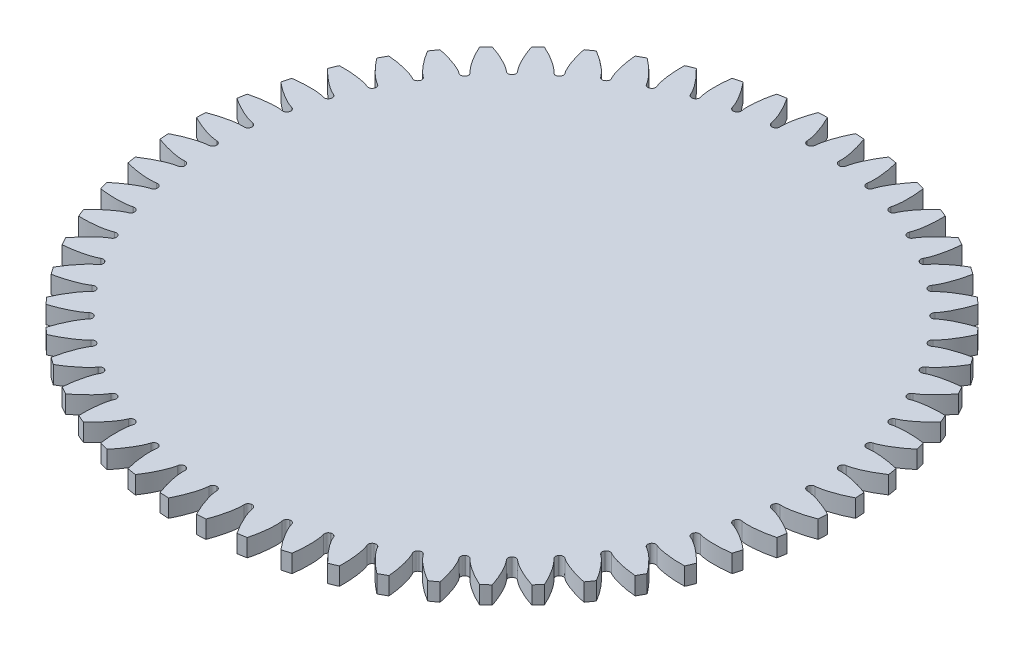
from build123d import *

# Parameters (mm, degrees)
SKETCH1_R                = 118.382142857
BOSS_EXTRUDE1_DEPTH      = 6.35
CUT_EXTRUDE1_DEPTH       = 6.35
FILLET1_R                = 1.369579486
CIRPATTERN2_COUNT        = 56
FILLET1_OF_CIRPATTERN2_R = 1.369579486


with BuildPart() as part:
    # Sketch1 → Boss-Extrude1 (new body)
    with BuildSketch(Plane(origin=(0, 0, 0), x_dir=(1, 0, 0), z_dir=(0, 1, 0))):
        Circle(SKETCH1_R)
    extrude(amount=BOSS_EXTRUDE1_DEPTH)

    # Sketch2 → Cut-Extrude1 (cut)
    with BuildSketch(Plane(origin=(0, 6.35, 0), x_dir=(1, 0, 0), z_dir=(0, 1, 0))):
        with BuildLine():
            Line((107.397586441, 1.411881728), (106.01316094, 1.393681645))
            ThreePointArc((106.01316094, 1.393681645), (106.022321429, 0), (106.01316094, -1.393681645))
            Line((106.01316094, -1.393681645), (107.397586441, -1.411881728))
            add(Edge.make_bspline(
                [(107.397586441, -1.411881728), (107.414640014, -1.412273178), (107.462463824, -1.413889125), (107.552848194, -1.418990064), (107.700290393, -1.430220367), (107.888087637, -1.448804059), (108.130732036, -1.477734499), (108.416446195, -1.518134278), (108.730294702, -1.569156647), (109.07157673, -1.631820907), (109.411887749, -1.700667187), (109.751194021, -1.775240573), (110.089030556, -1.854846983), (110.49804534, -1.95756771), (110.988183211, -2.089487133), (111.560584877, -2.256440262), (112.209156699, -2.460856515), (112.869459916, -2.685326699), (113.51860176, -2.919468999), (114.173745296, -3.171314388), (114.807113624, -3.425810832), (115.464207454, -3.705835066), (116.070337141, -3.972280508), (116.748518174, -4.288180471), (117.295552055, -4.548185322), (117.859858994, -4.83128941), (118.134395944, -4.971221843), (118.274652592, -5.043639719)],
                knots=[0, 0, 0, 0, 0, 0.005376749, 0.015083688, 0.02853182, 0.04661014, 0.064854849, 0.092110526, 0.119476176, 0.146842496, 0.174208854, 0.201574956, 0.228941013, 0.256307345, 0.307035032, 0.361767352, 0.416499661, 0.471231937, 0.525964282, 0.580696616, 0.635428982, 0.690161387, 0.744893688, 0.799626082, 0.854358407, 0.909090914, 0.909090914, 0.909090914, 0.909090914, 0.909090914], degree=4))
            ThreePointArc((118.274652592, -5.043639719), (118.382142857, 0), (118.274652592, 5.043639719))
            add(Edge.make_bspline(
                [(107.397586441, 1.411881728), (107.414640014, 1.412273178), (107.462463824, 1.413889125), (107.552848194, 1.418990064), (107.700290393, 1.430220367), (107.888087637, 1.448804059), (108.130732036, 1.477734499), (108.416446195, 1.518134278), (108.730294702, 1.569156647), (109.07157673, 1.631820907), (109.411887749, 1.700667187), (109.751194021, 1.775240573), (110.089030556, 1.854846983), (110.49804534, 1.95756771), (110.988183211, 2.089487133), (111.560584877, 2.256440262), (112.209156699, 2.460856515), (112.869459916, 2.685326699), (113.51860176, 2.919468999), (114.173745296, 3.171314388), (114.807113624, 3.425810832), (115.464207454, 3.705835066), (116.070337141, 3.972280508), (116.748518174, 4.288180471), (117.295552055, 4.548185322), (117.859858994, 4.83128941), (118.134395944, 4.971221843), (118.274652592, 5.043639719)],
                knots=[0, 0, 0, 0, 0, 0.005376749, 0.015083688, 0.02853182, 0.04661014, 0.064854849, 0.092110526, 0.119476176, 0.146842496, 0.174208854, 0.201574956, 0.228941013, 0.256307345, 0.307035032, 0.361767352, 0.416499661, 0.471231937, 0.525964282, 0.580696616, 0.635428982, 0.690161387, 0.744893688, 0.799626082, 0.854358407, 0.909090914, 0.909090914, 0.909090914, 0.909090914, 0.909090914], degree=4))
        make_face()
    cut_extrude1 = extrude(amount=-CUT_EXTRUDE1_DEPTH, mode=Mode.SUBTRACT)

    # Fillet1
    fillet1_edges = [part.edges().sort_by_distance(p)[0] for p in [
        (106.01316094, 3.175, 1.393681645),
        (106.01316094, 3.175, -1.393681645),
    ]]
    fillet(fillet1_edges, radius=FILLET1_R)

    # CirPattern2: Cut-Extrude1 ×56 about axis
    cirpattern2_axis = Axis((0, 6.35, 0), (0, -1, 0))
    for i in range(1, CIRPATTERN2_COUNT):
        add(cut_extrude1.rotate(cirpattern2_axis, i * 360 / CIRPATTERN2_COUNT), mode=Mode.SUBTRACT)

    # Fillet1 of CirPattern2
    fillet1_of_cirpattern2_edges = [part.edges().sort_by_distance(p)[0] for p in [
        (105.190529601, 3.175, 13.254626492),
        (105.502615271, 3.175, 10.484789558),
        (103.045066318, 3.175, 24.94888672),
        (103.665313001, 3.175, 22.231408448),
        (99.603751539, 3.175, 36.329400222),
        (100.524359271, 3.175, 33.698454478),
        (94.909861792, 3.175, 47.253050438),
        (96.119253398, 3.175, 44.741722891),
        (89.022425466, 3.175, 57.582466128),
        (90.505392144, 3.175, 55.222338179),
        (82.015480487, 3.175, 67.187748895),
        (83.753373072, 3.175, 65.008500523),
        (73.977143254, 3.175, 75.948106738),
        (75.948106738, 3.175, 73.977143254),
        (65.008500523, 3.175, 83.753373072),
        (67.187748895, 3.175, 82.015480487),
        (55.222338179, 3.175, 90.505392144),
        (57.582466128, 3.175, 89.022425466),
        (44.741722891, 3.175, 96.119253398),
        (47.253050438, 3.175, 94.909861792),
        (33.698454478, 3.175, 100.524359271),
        (36.329400222, 3.175, 99.603751539),
        (22.231408448, 3.175, 103.665313001),
        (24.94888672, 3.175, 103.045066318),
        (10.484789558, 3.175, 105.502615271),
        (13.254626492, 3.175, 105.190529601),
        (-1.393681645, 3.175, 106.01316094),
        (1.393681645, 3.175, 106.01316094),
        (-13.254626492, 3.175, 105.190529601),
        (-10.484789558, 3.175, 105.502615271),
        (-24.94888672, 3.175, 103.045066318),
        (-22.231408448, 3.175, 103.665313001),
        (-36.329400222, 3.175, 99.603751539),
        (-33.698454478, 3.175, 100.524359271),
        (-47.253050438, 3.175, 94.909861792),
        (-44.741722891, 3.175, 96.119253398),
        (-57.582466128, 3.175, 89.022425466),
        (-55.222338179, 3.175, 90.505392144),
        (-67.187748895, 3.175, 82.015480487),
        (-65.008500523, 3.175, 83.753373072),
        (-75.948106738, 3.175, 73.977143254),
        (-73.977143254, 3.175, 75.948106738),
        (-83.753373072, 3.175, 65.008500523),
        (-82.015480487, 3.175, 67.187748895),
        (-90.505392144, 3.175, 55.222338179),
        (-89.022425466, 3.175, 57.582466128),
        (-96.119253398, 3.175, 44.741722891),
        (-94.909861792, 3.175, 47.253050438),
        (-100.524359271, 3.175, 33.698454478),
        (-99.603751539, 3.175, 36.329400222),
        (-103.665313001, 3.175, 22.231408448),
        (-103.045066318, 3.175, 24.94888672),
        (-105.502615271, 3.175, 10.484789558),
        (-105.190529601, 3.175, 13.254626492),
        (-106.01316094, 3.175, -1.393681645),
        (-106.01316094, 3.175, 1.393681645),
        (-105.190529601, 3.175, -13.254626492),
        (-105.502615271, 3.175, -10.484789558),
        (-103.045066318, 3.175, -24.94888672),
        (-103.665313001, 3.175, -22.231408448),
        (-99.603751539, 3.175, -36.329400222),
        (-100.524359271, 3.175, -33.698454478),
        (-94.909861792, 3.175, -47.253050438),
        (-96.119253398, 3.175, -44.741722891),
        (-89.022425466, 3.175, -57.582466128),
        (-90.505392144, 3.175, -55.222338179),
        (-82.015480487, 3.175, -67.187748895),
        (-83.753373072, 3.175, -65.008500523),
        (-73.977143254, 3.175, -75.948106738),
        (-75.948106738, 3.175, -73.977143254),
        (-65.008500523, 3.175, -83.753373072),
        (-67.187748895, 3.175, -82.015480487),
        (-55.222338179, 3.175, -90.505392144),
        (-57.582466128, 3.175, -89.022425466),
        (-44.741722891, 3.175, -96.119253398),
        (-47.253050438, 3.175, -94.909861792),
        (-33.698454478, 3.175, -100.524359271),
        (-36.329400222, 3.175, -99.603751539),
        (-22.231408448, 3.175, -103.665313001),
        (-24.94888672, 3.175, -103.045066318),
        (-10.484789558, 3.175, -105.502615271),
        (-13.254626492, 3.175, -105.190529601),
        (1.393681645, 3.175, -106.01316094),
        (-1.393681645, 3.175, -106.01316094),
        (13.254626492, 3.175, -105.190529601),
        (10.484789558, 3.175, -105.502615271),
        (24.94888672, 3.175, -103.045066318),
        (22.231408448, 3.175, -103.665313001),
        (36.329400222, 3.175, -99.603751539),
        (33.698454478, 3.175, -100.524359271),
        (47.253050438, 3.175, -94.909861792),
        (44.741722891, 3.175, -96.119253398),
        (57.582466128, 3.175, -89.022425466),
        (55.222338179, 3.175, -90.505392144),
        (67.187748895, 3.175, -82.015480487),
        (65.008500523, 3.175, -83.753373072),
        (75.948106738, 3.175, -73.977143254),
        (73.977143254, 3.175, -75.948106738),
        (83.753373072, 3.175, -65.008500523),
        (82.015480487, 3.175, -67.187748895),
        (90.505392144, 3.175, -55.222338179),
        (89.022425466, 3.175, -57.582466128),
        (96.119253398, 3.175, -44.741722891),
        (94.909861792, 3.175, -47.253050438),
        (100.524359271, 3.175, -33.698454478),
        (99.603751539, 3.175, -36.329400222),
        (103.665313001, 3.175, -22.231408448),
        (103.045066318, 3.175, -24.94888672),
        (105.502615271, 3.175, -10.484789558),
        (105.190529601, 3.175, -13.254626492),
    ]]
    fillet(fillet1_of_cirpattern2_edges, radius=FILLET1_OF_CIRPATTERN2_R)


solid = part.part
